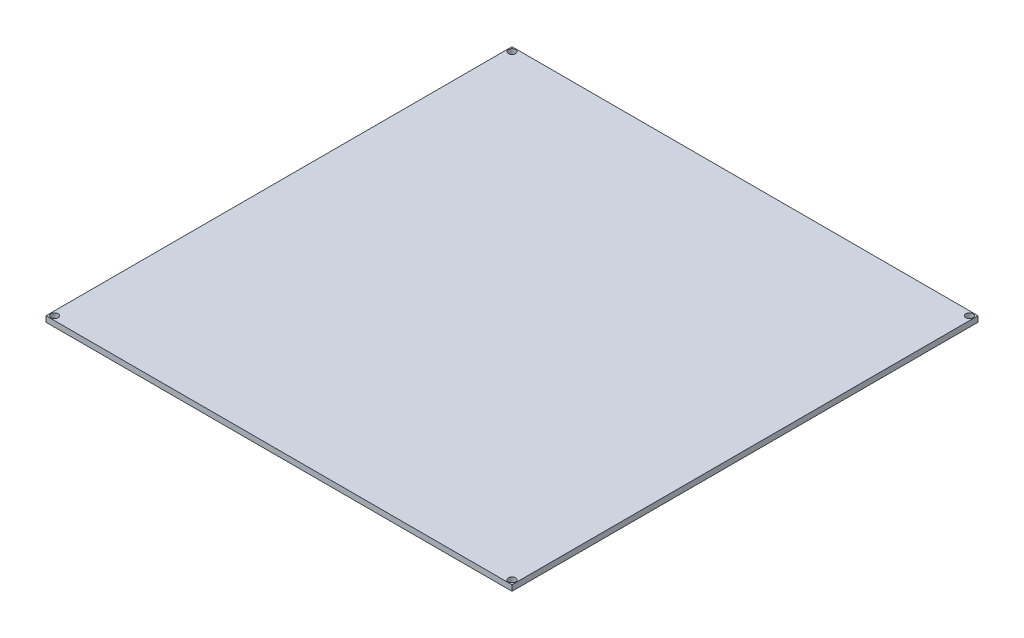
from build123d import *

# Parameters (mm, degrees)
SKETCH1_W           = 327
SKETCH1_H           = 327
SKETCH1_R           = 2.5
BOSS_EXTRUDE1_DEPTH = 4


with BuildPart() as part:
    # Sketch1 → Boss-Extrude1 (new body)
    with BuildSketch(Plane(origin=(0, 0, 0), x_dir=(1, 0, 0), z_dir=(0, 1, 0))):
        with Locations((-12.5, -64.630434783)):
            Rectangle(SKETCH1_W, SKETCH1_H)
        with Locations((-173, -225.130434783)):
            Circle(SKETCH1_R, mode=Mode.SUBTRACT)
        with Locations((-173, 95.869565217)):
            Circle(SKETCH1_R, mode=Mode.SUBTRACT)
        with Locations((148, 95.869565217)):
            Circle(SKETCH1_R, mode=Mode.SUBTRACT)
        with Locations((148, -225.130434783)):
            Circle(SKETCH1_R, mode=Mode.SUBTRACT)
    extrude(amount=BOSS_EXTRUDE1_DEPTH)


solid = part.part
